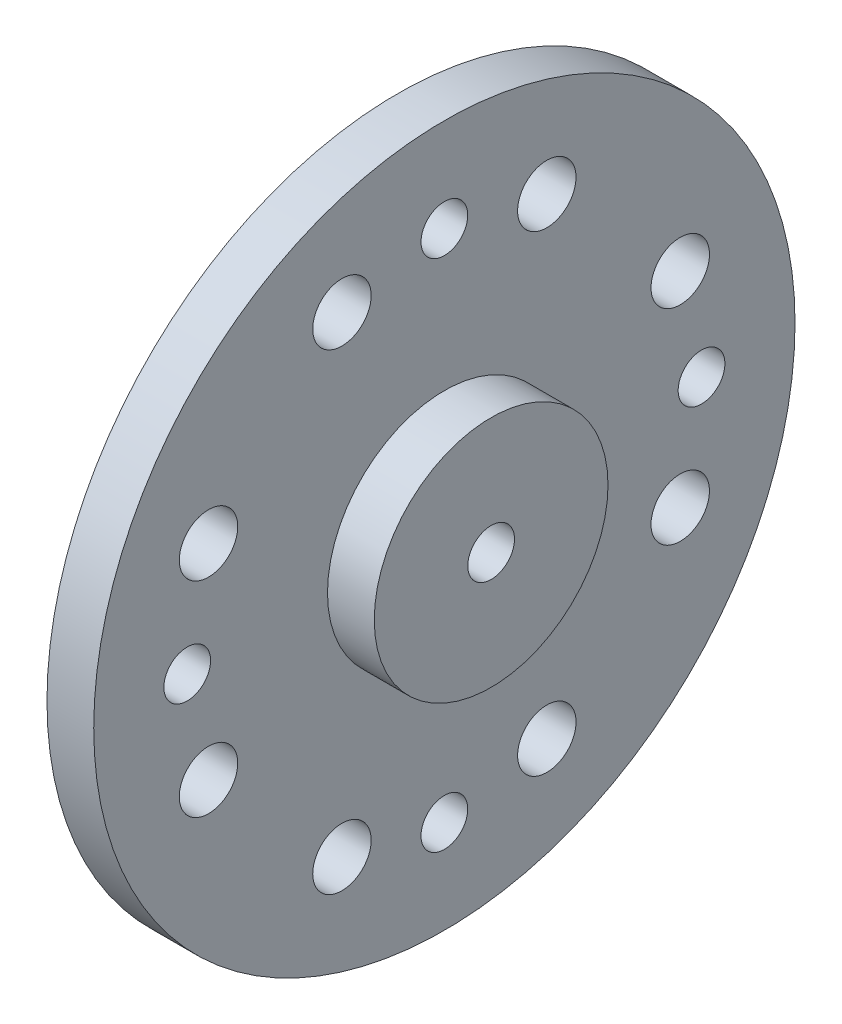
from build123d import *

# Parameters (mm, degrees)
SKETCH3_R           = 1.5
EXTRUDE1_DEPTH      = 4
SKETCH4_R           = 1
SKETCH4_R_2         = 1.25
EXTRUDE2_DEPTH      = 4
SKETCH5_R           = 5
SKETCH5_R_2         = 1
BOSS_EXTRUDE1_DEPTH = 2
SKETCH6_R           = 15
SKETCH6_R_2         = 5
CUT_EXTRUDE2_DEPTH  = 1


with BuildPart() as part:
    # Sketch1 → Revolve1 (revolve)
    with BuildSketch(Plane.XY):
        Polygon((1.809375, 15), (1.190625, 15), (0, 15), (0, 14), (0, 0), (3, 0), (3, 14), (3, 15), align=None)
    revolve(axis=Axis((0, 0, 0), (1, 0, 0)))

    # Sketch3 → Extrude1 (cut, through all)
    with BuildSketch(Plane(origin=(3, 0, 0), x_dir=(0, 0, -1), z_dir=(1, 0, 0))):
        Circle(SKETCH3_R)
    extrude(amount=-EXTRUDE1_DEPTH, mode=Mode.SUBTRACT)

    # Sketch4 → Extrude2 (cut, through all)
    with BuildSketch(Plane(origin=(3, 0, 0), x_dir=(0, 0, -1), z_dir=(1, 0, 0))):
        with Locations((0, 11)):
            Circle(SKETCH4_R)
        with Locations((-4.381841494, 10.089572098)):
            Circle(SKETCH4_R_2)
        with Locations((4.381841494, 10.089572098)):
            Circle(SKETCH4_R_2)
        with Locations((10.089572098, -4.381841494)):
            Circle(SKETCH4_R_2)
        with Locations((11, 0)):
            Circle(SKETCH4_R)
        with Locations((10.089572098, 4.381841494)):
            Circle(SKETCH4_R_2)
        with Locations((-4.381841494, -10.089572098)):
            Circle(SKETCH4_R_2)
        with Locations((0, -11)):
            Circle(SKETCH4_R)
        with Locations((4.381841494, -10.089572098)):
            Circle(SKETCH4_R_2)
        with Locations((-10.089572098, 4.381841494)):
            Circle(SKETCH4_R_2)
        with Locations((-11, 0)):
            Circle(SKETCH4_R)
        with Locations((-10.089572098, -4.381841494)):
            Circle(SKETCH4_R_2)
    extrude(amount=-EXTRUDE2_DEPTH, mode=Mode.SUBTRACT)

    # Sketch5 → Boss-Extrude1 (add)
    with BuildSketch(Plane(origin=(3, 0, 0), x_dir=(0, 0, -1), z_dir=(1, 0, 0))):
        Circle(SKETCH5_R)
        Circle(SKETCH5_R_2, mode=Mode.SUBTRACT)
    extrude(amount=BOSS_EXTRUDE1_DEPTH)

    # Sketch6 → Cut-Extrude2 (cut)
    with BuildSketch(Plane.ZY):
        Circle(SKETCH6_R)
        Circle(SKETCH6_R_2, mode=Mode.SUBTRACT)
    extrude(amount=-CUT_EXTRUDE2_DEPTH, mode=Mode.SUBTRACT)


solid = part.part
